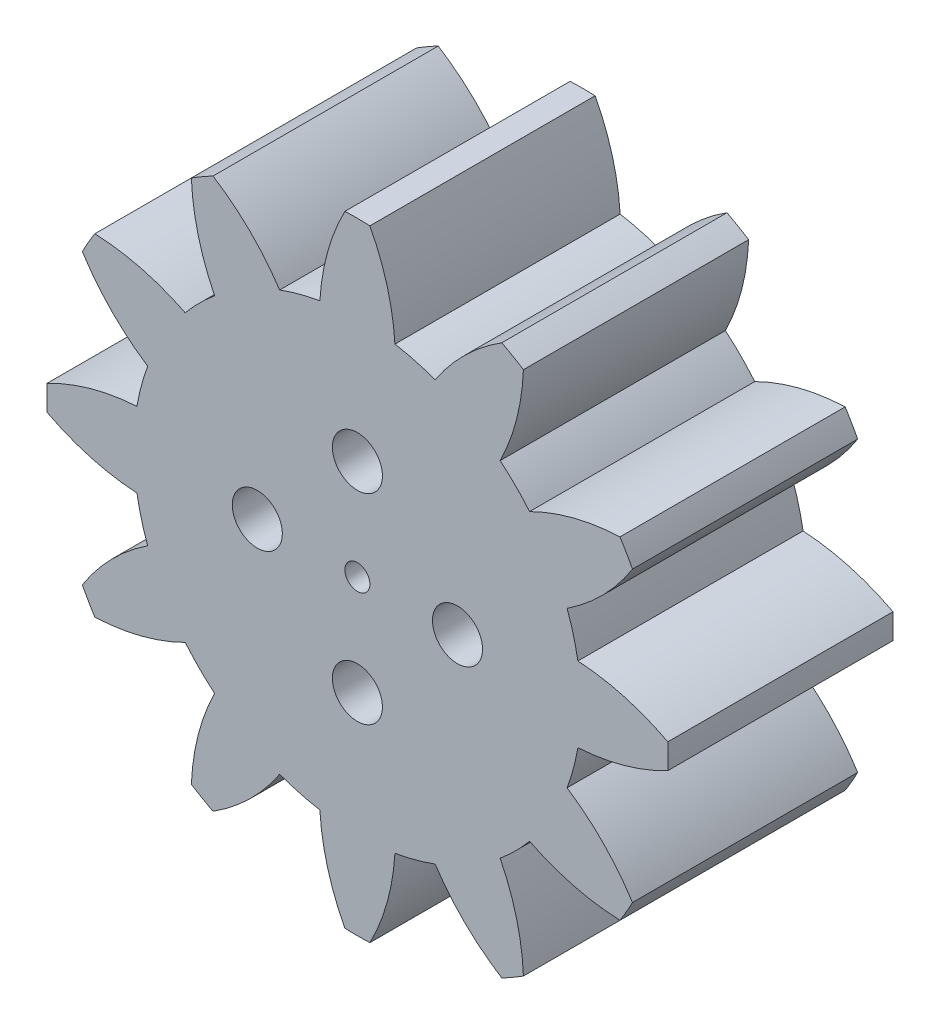
from build123d import *

# Parameters (mm, degrees)
EXTRUDE_1_DEPTH          = 18
SKETCH_2_R               = 17.875
SKETCH_2_R_2             = 1
EXTRUDE_2_DEPTH          = 18
PATTERN_CIRCULAR_3_COUNT = 12
SKETCH_3_R               = 1.1
CUT_EXTRUDE_1_DEPTH      = 19
PATTERN_CIRCULAR_4_COUNT = 4
SKETCH_4_R               = 2
CUT_EXTRUDE_2_DEPTH      = 10


with BuildPart() as part:
    # 草图1 → 凸台-拉伸1 (new body)
    with BuildSketch(Plane.XY):
        with BuildLine():
            ThreePointArc((3, 17.621453544), (0, 17.875), (-3, 17.621453544))
            ThreePointArc((-3, 17.621453544), (-2.381034791, 21.321544102), (-1, 24.809599575))
            ThreePointArc((-1, 24.809599575), (0, 24.830037117), (1, 24.809599575))
            ThreePointArc((1, 24.809599575), (2.381034791, 21.321544102), (3, 17.621453544))
        make_face()
    extrude_1 = extrude(amount=EXTRUDE_1_DEPTH)

    # 草图2 → 凸台-拉伸2 (add)
    with BuildSketch(Plane.XY):
        Circle(SKETCH_2_R)
        Circle(SKETCH_2_R_2, mode=Mode.SUBTRACT)
    extrude(amount=EXTRUDE_2_DEPTH)

    # 阵列(圆周)3: 凸台-拉伸1 ×12 about axis
    pattern_circular_3_axis = Axis((0, 0, 0), (0, 0, 1))
    for i in range(1, PATTERN_CIRCULAR_3_COUNT):
        add(extrude_1.rotate(pattern_circular_3_axis, i * 360 / PATTERN_CIRCULAR_3_COUNT))

    # 草图3 → 切除-拉伸1 (cut, through all)
    with BuildSketch(Plane(origin=(0, 0, 0), x_dir=(-1, 0, 0), z_dir=(0, 0, -1))):
        with Locations((0, 8)):
            Circle(SKETCH_3_R)
    cut_extrude_1 = extrude(amount=-CUT_EXTRUDE_1_DEPTH, mode=Mode.SUBTRACT)

    # 阵列(圆周)4: 切除-拉伸1 ×4 about axis
    pattern_circular_4_axis = Axis((0, 0, 0), (0, 0, 1))
    for i in range(1, PATTERN_CIRCULAR_4_COUNT):
        add(cut_extrude_1.rotate(pattern_circular_4_axis, i * 360 / PATTERN_CIRCULAR_4_COUNT), mode=Mode.SUBTRACT)

    # 草图4 → 切除-拉伸2 (cut)
    with BuildSketch(Plane.XY.offset(18)):
        with Locations((0, 8)):
            Circle(SKETCH_4_R)
        with Locations((8, 0)):
            Circle(SKETCH_4_R)
        with Locations((0, -8)):
            Circle(SKETCH_4_R)
        with Locations((-8, 0)):
            Circle(SKETCH_4_R)
    extrude(amount=-CUT_EXTRUDE_2_DEPTH, mode=Mode.SUBTRACT)


solid = part.part
